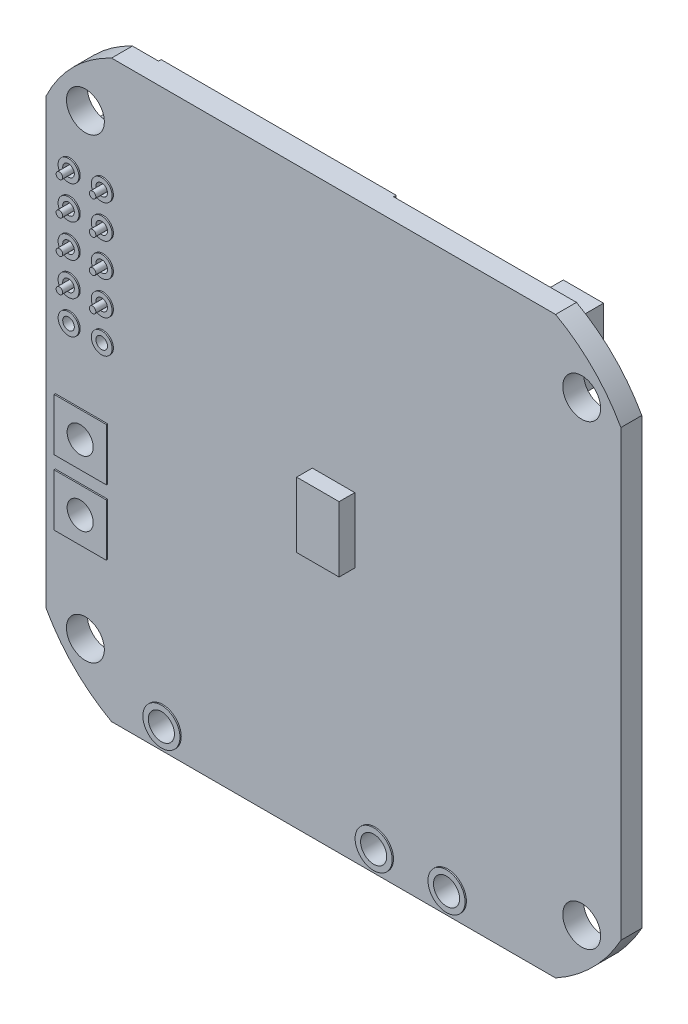
from build123d import *

# Parameters (mm, degrees)
SALIENTE_EXTRUIR1_DEPTH    = 0.8
CROQUIS2_R                 = 1.45
CORTAR_EXTRUIR1_DEPTH      = 32.153811966
CROQUIS3_W                 = 3.25
CROQUIS3_H                 = 5
SALIENTE_EXTRUIR2_DEPTH    = 1.2
CROQUIS4_R                 = 0.445
CORTAR_EXTRUIR2_DEPTH      = 32.238437861
CROQUIS5_R                 = 0.79739254
CROQUIS5_R_2               = 0.445
CROQUIS5_W                 = 4
CROQUIS5_H                 = 4
SALIENTE_EXTRUIR3_DEPTH    = 0.9
CORTAR_EXTRUIR3_DEPTH      = 32.247559905
CORTAR_EXTRUIR3_DEPTH_BACK = 32.247559905
CROQUIS6_R                 = 1
CROQUIS7_R                 = 1
CORTAR_EXTRUIR4_DEPTH      = 10
CROQUIS8_W                 = 3
CROQUIS8_H                 = 2.5
SALIENTE_EXTRUIR4_DEPTH    = 1.2
CROQUIS9_R                 = 0.75
SALIENTE_EXTRUIR5_DEPTH    = 0.8
CROQUIS10_W                = 5
CROQUIS10_H                = 5
SALIENTE_EXTRUIR6_DEPTH    = 0.9
SALIENTE_EXTRUIR7_START    = 0.1
CROQUIS11_R                = 1
SALIENTE_EXTRUIR7_DEPTH    = 0.1
SALIENTE_EXTRUIR8_DEPTH    = 0.75
CROQUIS13_W                = 3.080395022
CROQUIS13_H                = 5.233680862
SALIENTE_EXTRUIR9_DEPTH    = 2.65
CROQUIS14_W                = 3.82
CROQUIS14_H                = 3.82
SALIENTE_EXTRUIR10_DEPTH   = 3
CROQUIS30_R                = 1.419915385
CROQUIS30_R_2              = 1
SALIENTE_EXTRUIR17_DEPTH   = 0.1
CROQUIS29_W                = 3.5
CROQUIS29_H                = 1.5
SALIENTE_EXTRUIR16_DEPTH   = 0.5
CROQUIS31_W                = 18
CROQUIS31_H                = 19.35
BOSS_EXTRUDE1_DEPTH        = 0.2
CHAFL_N1_SIZE              = 1
CROQUIS32_R                = 0.65
SALIENTE_EXTRUIR18_DEPTH   = 1.6
CROQUIS33_R                = 0.25
SALIENTE_EXTRUIR19_DEPTH   = 2.5
CROQUIS34_R                = 0.65
CROQUIS34_R_2              = 0.64
CROQUIS34_R_3              = 0.664142136
SALIENTE_EXTRUIR20_DEPTH   = 3


with BuildPart() as part:
    # Croquis1 → Saliente-Extruir1 (new, symmetric)
    with BuildSketch(Plane.XY):
        with BuildLine():
            Line((-22, 17), (-22, -17))
            ThreePointArc((-22, -17), (-19.853553391, -19.853553391), (-17, -22))
            Line((-17, -22), (17, -22))
            ThreePointArc((17, -22), (19.853553391, -19.853553391), (22, -17))
            Line((22, -17), (22, 17))
            ThreePointArc((22, 17), (19.853553391, 19.853553391), (17, 22))
            Line((17, 22), (-17, 22))
            ThreePointArc((-17, 22), (-19.933555475, 19.933555475), (-22, 17))
        make_face()
    extrude(amount=SALIENTE_EXTRUIR1_DEPTH, both=True)

    # Croquis2 → Cortar-Extruir1 (cut, through all)
    with BuildSketch(Plane.XY.offset(0.8)):
        with Locations((-19, 17.5)):
            Circle(CROQUIS2_R)
        with Locations((19, 17.5)):
            Circle(CROQUIS2_R)
        with Locations((19, -17.5)):
            Circle(CROQUIS2_R)
        with Locations((-19, -17.5)):
            Circle(CROQUIS2_R)
    extrude(amount=-CORTAR_EXTRUIR1_DEPTH, mode=Mode.SUBTRACT)

    # Croquis3 → Saliente-Extruir2 (add)
    with BuildSketch(Plane.XY.offset(0.8)):
        Rectangle(CROQUIS3_W, CROQUIS3_H)
    extrude(amount=SALIENTE_EXTRUIR2_DEPTH)

    # Croquis4 → Cortar-Extruir2 (cut, through all)
    with BuildSketch(Plane(origin=(0, 0, -0.8), x_dir=(-1, 0, 0), z_dir=(0, 0, -1))):
        with Locations((17.653, 13)):
            Circle(CROQUIS4_R)
        with Locations((20.193, 13)):
            Circle(CROQUIS4_R)
        with Locations((20.193, 10.46)):
            Circle(CROQUIS4_R)
        with Locations((20.193, 7.92)):
            Circle(CROQUIS4_R)
        with Locations((20.193, 5.38)):
            Circle(CROQUIS4_R)
        with Locations((20.193, 2.84)):
            Circle(CROQUIS4_R)
        with Locations((17.653, 10.46)):
            Circle(CROQUIS4_R)
        with Locations((17.653, 7.92)):
            Circle(CROQUIS4_R)
        with Locations((17.653, 5.38)):
            Circle(CROQUIS4_R)
        with Locations((17.653, 2.84)):
            Circle(CROQUIS4_R)
    extrude(amount=-CORTAR_EXTRUIR2_DEPTH, mode=Mode.SUBTRACT)

    # Croquis5 → Saliente-Extruir3 (add, symmetric)
    # profile 1 of 12: a face of its own
    with BuildSketch(Plane.XY):
        with Locations((-17.653, 2.84)):
            Circle(CROQUIS5_R)
        with Locations((-17.653, 2.84)):
            Circle(CROQUIS5_R_2, mode=Mode.SUBTRACT)
    # profile 2 of 12: a face of its own
    with BuildSketch(Plane.XY):
        with Locations((-20.193, 2.84)):
            Circle(CROQUIS5_R)
        with Locations((-20.193, 2.84)):
            Circle(CROQUIS5_R_2, mode=Mode.SUBTRACT)
    # profile 3 of 12: a face of its own
    with BuildSketch(Plane.XY):
        with Locations((-20.193, 5.38)):
            Circle(CROQUIS5_R)
        with Locations((-20.193, 5.38)):
            Circle(CROQUIS5_R_2, mode=Mode.SUBTRACT)
    # profile 4 of 12: a face of its own
    with BuildSketch(Plane.XY):
        with Locations((-17.653, 5.38)):
            Circle(CROQUIS5_R)
        with Locations((-17.653, 5.38)):
            Circle(CROQUIS5_R_2, mode=Mode.SUBTRACT)
    # profile 5 of 12: a face of its own
    with BuildSketch(Plane.XY):
        with Locations((-17.653, 7.92)):
            Circle(CROQUIS5_R)
        with Locations((-17.653, 7.92)):
            Circle(CROQUIS5_R_2, mode=Mode.SUBTRACT)
    # profile 6 of 12: a face of its own
    with BuildSketch(Plane.XY):
        with Locations((-17.653, 10.46)):
            Circle(CROQUIS5_R)
        with Locations((-17.653, 10.46)):
            Circle(CROQUIS5_R_2, mode=Mode.SUBTRACT)
    # profile 7 of 12: a face of its own
    with BuildSketch(Plane.XY):
        with Locations((-20.193, 7.92)):
            Circle(CROQUIS5_R)
        with Locations((-20.193, 7.92)):
            Circle(CROQUIS5_R_2, mode=Mode.SUBTRACT)
    # profile 8 of 12: a face of its own
    with BuildSketch(Plane.XY):
        with Locations((-20.193, 10.46)):
            Circle(CROQUIS5_R)
        with Locations((-20.193, 10.46)):
            Circle(CROQUIS5_R_2, mode=Mode.SUBTRACT)
    # profile 9 of 12: a face of its own
    with BuildSketch(Plane.XY):
        with Locations((-17.653, 13)):
            Circle(CROQUIS5_R)
        with Locations((-17.653, 13)):
            Circle(CROQUIS5_R_2, mode=Mode.SUBTRACT)
    # profile 10 of 12: a face of its own
    with BuildSketch(Plane.XY):
        with Locations((-20.193, 13)):
            Circle(CROQUIS5_R)
        with Locations((-20.193, 13)):
            Circle(CROQUIS5_R_2, mode=Mode.SUBTRACT)
    # profile 11 of 12: a face of its own
    with BuildSketch(Plane.XY):
        with Locations((-19.3, -4.4)):
            Rectangle(CROQUIS5_W, CROQUIS5_H)
    # profile 12 of 12: a face of its own
    with BuildSketch(Plane.XY):
        with Locations((-19.3, -9.4)):
            Rectangle(CROQUIS5_W, CROQUIS5_H)
    extrude(amount=SALIENTE_EXTRUIR3_DEPTH, both=True)

    # Croquis6 → Cortar-Extruir3 (cut, two sides: drawn at the far end of the back side and taken through both)
    with BuildSketch(Plane(origin=(0, 0, -0.9), x_dir=(-1, 0, 0), z_dir=(0, 0, -1)).offset(-CORTAR_EXTRUIR3_DEPTH_BACK)):
        with Locations((19.3, -4.4)):
            Circle(CROQUIS6_R)
        with Locations((19.3, -9.4)):
            Circle(CROQUIS6_R)
    extrude(amount=CORTAR_EXTRUIR3_DEPTH + CORTAR_EXTRUIR3_DEPTH_BACK, mode=Mode.SUBTRACT)

    # Croquis7 → Cortar-Extruir4 (cut)
    with BuildSketch(Plane(origin=(0, 0, -0.8), x_dir=(-1, 0, 0), z_dir=(0, 0, -1))):
        with Locations((-8.75, -20.32)):
            Circle(CROQUIS7_R)
        with Locations((-3.17, -20.32)):
            Circle(CROQUIS7_R)
        with Locations((13.08, -20.32)):
            Circle(CROQUIS7_R)
    extrude(amount=-CORTAR_EXTRUIR4_DEPTH, mode=Mode.SUBTRACT)

    # Croquis8 → Saliente-Extruir4 (add)
    with BuildSketch(Plane(origin=(0, 0, -0.8), x_dir=(-1, 0, 0), z_dir=(0, 0, -1))):
        with Locations((-19, 12.2)):
            Rectangle(CROQUIS8_W, CROQUIS8_H)
        with Locations((-19, 9.025)):
            Rectangle(CROQUIS8_W, CROQUIS8_H)
    extrude(amount=SALIENTE_EXTRUIR4_DEPTH)

    # Croquis9 → Saliente-Extruir5 (add)
    with BuildSketch(Plane(origin=(0, 0, -2), x_dir=(-1, 0, 0), z_dir=(0, 0, -1))):
        with Locations((-19, 12.2)):
            Circle(CROQUIS9_R)
        with Locations((-19, 9.025)):
            Circle(CROQUIS9_R)
    extrude(amount=SALIENTE_EXTRUIR5_DEPTH)

    # Croquis10 → Saliente-Extruir6 (add)
    with BuildSketch(Plane(origin=(0, 0, -0.8), x_dir=(-1, 0, 0), z_dir=(0, 0, -1))):
        with Locations((-13.5, -16.75)):
            Rectangle(CROQUIS10_W, CROQUIS10_H)
        with Locations((13.75, -14.7)):
            Rectangle(CROQUIS10_W, CROQUIS10_H)
        with Locations((8.387686328, -16.75)):
            Rectangle(CROQUIS10_W, CROQUIS10_H)
        with Locations((2.934297752, -16.75)):
            Rectangle(CROQUIS10_W, CROQUIS10_H)
        with Locations((-2.448267596, -14.7)):
            Rectangle(CROQUIS10_W, CROQUIS10_H)
        with Locations((-8.043302629, -14.7)):
            Rectangle(CROQUIS10_W, CROQUIS10_H)
    extrude(amount=SALIENTE_EXTRUIR6_DEPTH)

    # Croquis11 → Saliente-Extruir7 (add)
    # profile 1 of 3: a face of its own
    with BuildSketch(Plane(origin=(0, 0, -0.8), x_dir=(-1, 0, 0), z_dir=(0, 0, -1)).offset(SALIENTE_EXTRUIR7_START)):
        Polygon((-13.652894244, -19.522521794), (-10.45933095, -19.522521794), (-9.812366284, -18.875557129), (-7.528981863, -18.875557129), (-7.147566948, -19.256972043), (-7.147566948, -21.343674777), (-7.528981863, -21.725089692), (-13.830102074, -21.725089692), (-14.141358707, -21.413833058), (-14.141358707, -20.010986258), align=None)
        with Locations((-8.75, -20.32)):
            Circle(CROQUIS11_R, mode=Mode.SUBTRACT)
    # profile 2 of 3: a face of its own
    with BuildSketch(Plane(origin=(0, 0, -0.8), x_dir=(-1, 0, 0), z_dir=(0, 0, -1)).offset(SALIENTE_EXTRUIR7_START)):
        Polygon((8.172318821, -19.522521794), (11.198277852, -19.522521794), (12.022450347, -18.698349299), (14.296231203, -18.698349299), (14.77845979, -19.180577887), (14.77845979, -21.242861104), (14.296231203, -21.725089692), (7.995110992, -21.725089692), (7.683854358, -21.413833058), (7.683854358, -20.010986258), align=None)
        with Locations((13.08, -20.32)):
            Circle(CROQUIS11_R, mode=Mode.SUBTRACT)
    # profile 3 of 3: a face of its own
    with BuildSketch(Plane(origin=(0, 0, -0.8), x_dir=(-1, 0, 0), z_dir=(0, 0, -1)).offset(SALIENTE_EXTRUIR7_START)):
        Polygon((2.263089361, -20.010986258), (1.774624897, -19.522521794), (-1.418938397, -19.522521794), (-2.065903062, -18.875557129), (-4.349287484, -18.875557129), (-4.730702399, -19.256972043), (-4.730702399, -21.343674777), (-4.349287484, -21.725089692), (1.951832727, -21.725089692), (2.263089361, -21.413833058), align=None)
        with Locations((-3.17, -20.32)):
            Circle(CROQUIS11_R, mode=Mode.SUBTRACT)
    extrude(amount=-SALIENTE_EXTRUIR7_DEPTH)

    # Croquis12 → Saliente-Extruir8 (add)
    with BuildSketch(Plane(origin=(0, 0, -0.8), x_dir=(-1, 0, 0), z_dir=(0, 0, -1))):
        Polygon((-19.575208836, -2.789767852), (-13.48447481, -8.880501877), (-7.393740785, -2.789767852), (-13.48447481, 3.300966173), align=None)
    extrude(amount=SALIENTE_EXTRUIR8_DEPTH)

    # Croquis13 → Saliente-Extruir9 (add)
    with BuildSketch(Plane(origin=(0, 0, -0.8), x_dir=(-1, 0, 0), z_dir=(0, 0, -1))):
        with Locations((-14.88146784, 17.715085573)):
            Rectangle(CROQUIS13_W, CROQUIS13_H)
    extrude(amount=SALIENTE_EXTRUIR9_DEPTH)

    # Croquis14 → Saliente-Extruir10 (add)
    with BuildSketch(Plane(origin=(0, 0, -0.8), x_dir=(-1, 0, 0), z_dir=(0, 0, -1))):
        with Locations((-10.141101814, 15.498369959)):
            Rectangle(CROQUIS14_W, CROQUIS14_H)
    extrude(amount=SALIENTE_EXTRUIR10_DEPTH)

    # Croquis30 → Saliente-Extruir17 (add)
    # profile 1 of 3: a face of its own
    with BuildSketch(Plane.XY.offset(0.8)):
        with Locations((-13.08, -20.32)):
            Circle(CROQUIS30_R)
        with Locations(Location((-13.08, -20.32, 0), (0, 0, 180))):
            Circle(CROQUIS30_R_2, mode=Mode.SUBTRACT)
    # profile 2 of 3: a face of its own
    with BuildSketch(Plane.XY.offset(0.8)):
        with Locations((8.75, -20.32)):
            Circle(CROQUIS30_R)
        with Locations(Location((8.75, -20.32, 0), (0, 0, 180))):
            Circle(CROQUIS30_R_2, mode=Mode.SUBTRACT)
    # profile 3 of 3: a face of its own
    with BuildSketch(Plane.XY.offset(0.8)):
        with Locations((3.17, -20.32)):
            Circle(CROQUIS30_R)
        with Locations(Location((3.17, -20.32, 0), (0, 0, 180))):
            Circle(CROQUIS30_R_2, mode=Mode.SUBTRACT)
    extrude(amount=SALIENTE_EXTRUIR17_DEPTH)

    # Croquis29 → Saliente-Extruir16 (add)
    with BuildSketch(Plane(origin=(0, 0, -0.8), x_dir=(-1, 0, 0), z_dir=(0, 0, -1))):
        with Locations((12.25, 0.75)):
            Rectangle(CROQUIS29_W, CROQUIS29_H)
        with Locations((12.25, -1.4)):
            Rectangle(CROQUIS29_W, CROQUIS29_H)
        with Locations((4.5, 0.75)):
            Rectangle(CROQUIS29_W, CROQUIS29_H)
    extrude(amount=SALIENTE_EXTRUIR16_DEPTH)

    # Croquis31 → Boss-Extrude1 (add)
    with BuildSketch(Plane(origin=(0, 0, -0.8), x_dir=(-1, 0, 0), z_dir=(0, 0, -1))):
        with Locations((6, 12.325)):
            Rectangle(CROQUIS31_W, CROQUIS31_H)
    extrude(amount=BOSS_EXTRUDE1_DEPTH)

    # Chaflán1
    chafl_n1_edges = [part.edges().sort_by_distance(p)[0] for p in [
        (12.051101814, 17.408369959, -2.3),
        (12.051101814, 13.588369959, -2.3),
        (8.231101814, 13.588369959, -2.3),
        (8.231101814, 17.408369959, -2.3),
    ]]
    chamfer(chafl_n1_edges, length=CHAFL_N1_SIZE)

    # Croquis32 → Saliente-Extruir18 (add)
    with BuildSketch(Plane(origin=(0, 0, -0.9), x_dir=(-1, 0, 0), z_dir=(0, 0, -1))):
        with Locations((17.653, 13)):
            Circle(CROQUIS32_R)
        with Locations((20.193, 13)):
            Circle(CROQUIS32_R)
        with Locations((20.193, 10.46)):
            Circle(CROQUIS32_R)
        with Locations((17.653, 10.46)):
            Circle(CROQUIS32_R)
        with Locations((17.653, 7.92)):
            Circle(CROQUIS32_R)
        with Locations((20.193, 7.92)):
            Circle(CROQUIS32_R)
        with Locations((20.193, 5.38)):
            Circle(CROQUIS32_R)
        with Locations((17.653, 5.38)):
            Circle(CROQUIS32_R)
    extrude(amount=SALIENTE_EXTRUIR18_DEPTH)

    # Croquis33 → Saliente-Extruir19 (add)
    with BuildSketch(Plane.XY.offset(-0.9)):
        with Locations(Location((-20.193, 13, 0), (0, 0, 180))):
            Circle(CROQUIS33_R)
        with Locations(Location((-17.653, 13, 0), (0, 0, 180))):
            Circle(CROQUIS33_R)
        with Locations(Location((-17.653, 10.46, 0), (0, 0, 180))):
            Circle(CROQUIS33_R)
        with Locations(Location((-20.193, 10.46, 0), (0, 0, 180))):
            Circle(CROQUIS33_R)
        with Locations(Location((-20.193, 7.92, 0), (0, 0, 180))):
            Circle(CROQUIS33_R)
        with Locations(Location((-17.653, 7.92, 0), (0, 0, 180))):
            Circle(CROQUIS33_R)
        with Locations(Location((-17.653, 5.38, 0), (0, 0, 180))):
            Circle(CROQUIS33_R)
        with Locations(Location((-20.193, 5.38, 0), (0, 0, 180))):
            Circle(CROQUIS33_R)
    extrude(amount=SALIENTE_EXTRUIR19_DEPTH)

    # Croquis34 → Saliente-Extruir20 (add)
    # profile 1 of 8: a face of its own
    with BuildSketch(Plane(origin=(0, 0, -2.5), x_dir=(-1, 0, 0), z_dir=(0, 0, -1))):
        Polygon((16.388, 14.110187818), (16.388, 11.920171354), (16.872841707, 11.735), (18.422628322, 11.735), (18.918, 11.889812182), (18.918, 14.110187818), (18.433158293, 14.265), (16.872841707, 14.265), align=None)
        with Locations((17.653, 13)):
            Circle(CROQUIS34_R, mode=Mode.SUBTRACT)
    # profile 2 of 8: a face of its own
    with BuildSketch(Plane(origin=(0, 0, -2.5), x_dir=(-1, 0, 0), z_dir=(0, 0, -1))):
        Polygon((18.928, 14.110187818), (18.928, 11.920171354), (19.412841707, 11.735), (20.962628322, 11.735), (21.458, 11.889812182), (21.458, 14.110187818), (20.973158293, 14.265), (19.412841707, 14.265), align=None)
        with Locations((20.193, 13)):
            Circle(CROQUIS34_R_2, mode=Mode.SUBTRACT)
    # profile 3 of 8: a face of its own
    with BuildSketch(Plane(origin=(0, 0, -2.5), x_dir=(-1, 0, 0), z_dir=(0, 0, -1))):
        Polygon((18.928, 11.570187818), (18.928, 9.380171354), (19.412841707, 9.195), (20.962628322, 9.195), (21.458, 9.349812182), (21.458, 11.570187818), (20.973158293, 11.725), (19.412841707, 11.725), align=None)
        with Locations((20.193, 10.46)):
            Circle(CROQUIS34_R_3, mode=Mode.SUBTRACT)
    # profile 4 of 8: a face of its own
    with BuildSketch(Plane(origin=(0, 0, -2.5), x_dir=(-1, 0, 0), z_dir=(0, 0, -1))):
        Polygon((16.388, 11.570187818), (16.388, 9.380171354), (16.872841707, 9.195), (18.422628322, 9.195), (18.918, 9.349812182), (18.918, 11.570187818), (18.433158293, 11.725), (16.872841707, 11.725), align=None)
        with Locations((17.653, 10.46)):
            Circle(CROQUIS34_R, mode=Mode.SUBTRACT)
    # profile 5 of 8: a face of its own
    with BuildSketch(Plane(origin=(0, 0, -2.5), x_dir=(-1, 0, 0), z_dir=(0, 0, -1))):
        Polygon((16.388, 9.030187818), (16.388, 6.840171354), (16.872841707, 6.655), (18.422628322, 6.655), (18.918, 6.809812182), (18.918, 9.030187818), (18.433158293, 9.185), (16.872841707, 9.185), align=None)
        with Locations((17.653, 7.92)):
            Circle(CROQUIS34_R, mode=Mode.SUBTRACT)
    # profile 6 of 8: a face of its own
    with BuildSketch(Plane(origin=(0, 0, -2.5), x_dir=(-1, 0, 0), z_dir=(0, 0, -1))):
        Polygon((18.928, 9.030187818), (18.928, 6.840171354), (19.412841707, 6.655), (20.962628322, 6.655), (21.458, 6.809812182), (21.458, 9.030187818), (20.973158293, 9.185), (19.412841707, 9.185), align=None)
        with Locations((20.193, 7.92)):
            Circle(CROQUIS34_R, mode=Mode.SUBTRACT)
    # profile 7 of 8: a face of its own
    with BuildSketch(Plane(origin=(0, 0, -2.5), x_dir=(-1, 0, 0), z_dir=(0, 0, -1))):
        Polygon((16.388, 6.490187818), (16.388, 4.300171354), (16.872841707, 4.115), (18.422628322, 4.115), (18.918, 4.269812182), (18.918, 6.490187818), (18.433158293, 6.645), (16.872841707, 6.645), align=None)
        with Locations((17.653, 5.38)):
            Circle(CROQUIS34_R, mode=Mode.SUBTRACT)
    # profile 8 of 8: a face of its own
    with BuildSketch(Plane(origin=(0, 0, -2.5), x_dir=(-1, 0, 0), z_dir=(0, 0, -1))):
        Polygon((18.928, 6.490187818), (18.928, 4.300171354), (19.412841707, 4.115), (20.962628322, 4.115), (21.458, 4.269812182), (21.458, 6.490187818), (20.973158293, 6.645), (19.412841707, 6.645), align=None)
        with Locations((20.193, 5.38)):
            Circle(CROQUIS34_R, mode=Mode.SUBTRACT)
    extrude(amount=SALIENTE_EXTRUIR20_DEPTH)


with BuildPart() as saliente_extruir20_piece_1:
    # of the separate pieces the step leaves, piece 1, a body of its own (saliente_extruir20_pieces)
    add(part.part.solids().sort_by_distance((11.051101814, 17.408369959, -0.8))[0])


with BuildPart() as saliente_extruir20_piece_2:
    # of the separate pieces the step leaves, piece 2, a body of its own (saliente_extruir20_pieces)
    add(part.part.solids().sort_by_distance((-18.303, 7.92, -5.5))[0])


with BuildPart() as saliente_extruir20_piece_3:
    # of the separate pieces the step leaves, piece 3, a body of its own (saliente_extruir20_pieces)
    add(part.part.solids().sort_by_distance((-18.303, 10.46, -5.5))[0])


with BuildPart() as saliente_extruir20_piece_4:
    # of the separate pieces the step leaves, piece 4, a body of its own (saliente_extruir20_pieces)
    add(part.part.solids().sort_by_distance((-18.303, 13, -5.5))[0])


with BuildPart() as saliente_extruir20_piece_5:
    # of the separate pieces the step leaves, piece 5, a body of its own (saliente_extruir20_pieces)
    add(part.part.solids().sort_by_distance((-20.843, 7.92, -5.5))[0])


with BuildPart() as saliente_extruir20_piece_6:
    # of the separate pieces the step leaves, piece 6, a body of its own (saliente_extruir20_pieces)
    add(part.part.solids().sort_by_distance((-18.303, 5.38, -5.5))[0])


with BuildPart() as saliente_extruir20_piece_7:
    # of the separate pieces the step leaves, piece 7, a body of its own (saliente_extruir20_pieces)
    add(part.part.solids().sort_by_distance((-20.843, 5.38, -5.5))[0])


with BuildPart() as saliente_extruir20_piece_8:
    # of the separate pieces the step leaves, piece 8, a body of its own (saliente_extruir20_pieces)
    add(part.part.solids().sort_by_distance((-18.928, 11.570187818, -2.5))[0])


solid = Compound([saliente_extruir20_piece_1.part, saliente_extruir20_piece_2.part, saliente_extruir20_piece_3.part, saliente_extruir20_piece_4.part, saliente_extruir20_piece_5.part, saliente_extruir20_piece_6.part, saliente_extruir20_piece_7.part, saliente_extruir20_piece_8.part])
